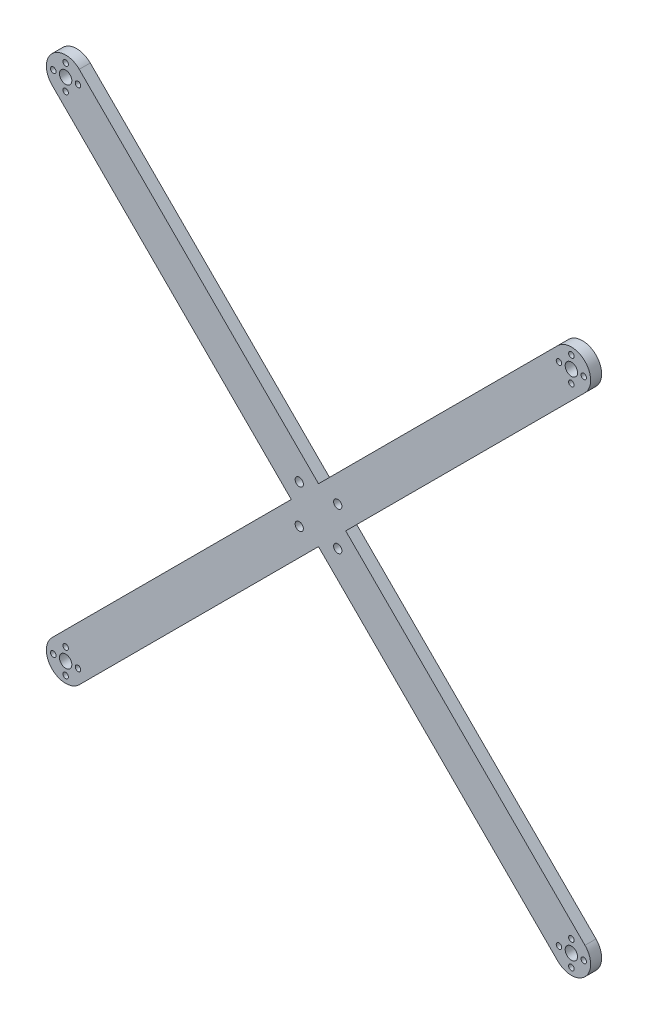
from build123d import *

# Parameters (mm, degrees)
CROQUIS1_R              = 1.5
CROQUIS1_R_2            = 1
CROQUIS1_R_3            = 1.004910311
CROQUIS1_R_4            = 2.25
SALIENTE_EXTRUIR1_DEPTH = 4


with BuildPart() as part:
    # Croquis1 → Saliente-Extruir1 (new body)
    with BuildSketch(Plane.XY):
        with BuildLine():
            Line((-72.974134086, -82.873629023), (14, 4.100505063))
            Line((14, 4.100505063), (100.974134086, -82.873629023))
            ThreePointArc((100.974134086, -82.873629023), (110.873629023, -82.873629023), (110.873629023, -72.974134086))
            Line((110.873629023, -72.974134086), (23.899494937, 14))
            Line((23.899494937, 14), (110.873629023, 100.974134086))
            ThreePointArc((110.873629023, 100.974134086), (110.873629023, 110.873629023), (100.974134086, 110.873629023))
            Line((100.974134086, 110.873629023), (14, 23.899494937))
            Line((14, 23.899494937), (-72.974134086, 110.873629023))
            ThreePointArc((-72.974134086, 110.873629023), (-82.873629023, 110.873629023), (-82.873629023, 100.974134086))
            Line((-82.873629023, 100.974134086), (4.100505063, 14))
            Line((4.100505063, 14), (-82.873629023, -72.974134086))
            ThreePointArc((-82.873629023, -72.974134086), (-82.873629023, -82.873629023), (-72.974134086, -82.873629023))
        make_face()
        with Locations((7, 7)):
            Circle(CROQUIS1_R, mode=Mode.SUBTRACT)
        with Locations((21, 7)):
            Circle(CROQUIS1_R, mode=Mode.SUBTRACT)
        with Locations((-73.423881554, -77.923881554)):
            Circle(CROQUIS1_R_2, mode=Mode.SUBTRACT)
        with Locations((-77.923881554, -82.423881554)):
            Circle(CROQUIS1_R_3, mode=Mode.SUBTRACT)
        with Locations((-82.423881554, -77.923881554)):
            Circle(CROQUIS1_R_2, mode=Mode.SUBTRACT)
        with Locations((-77.923881554, -73.423881554)):
            Circle(CROQUIS1_R_2, mode=Mode.SUBTRACT)
        with Locations((7, 21)):
            Circle(CROQUIS1_R, mode=Mode.SUBTRACT)
        with Locations((110.423881554, -77.923881554)):
            Circle(CROQUIS1_R_2, mode=Mode.SUBTRACT)
        with Locations((105.923881554, -82.423881554)):
            Circle(CROQUIS1_R_2, mode=Mode.SUBTRACT)
        with Locations((101.423881554, -77.923881554)):
            Circle(CROQUIS1_R_2, mode=Mode.SUBTRACT)
        with Locations((105.923881554, -73.423881554)):
            Circle(CROQUIS1_R_2, mode=Mode.SUBTRACT)
        with Locations((-73.423881554, 105.923881554)):
            Circle(CROQUIS1_R_2, mode=Mode.SUBTRACT)
        with Locations((-77.923881554, 101.423881554)):
            Circle(CROQUIS1_R_2, mode=Mode.SUBTRACT)
        with Locations((-82.423881554, 105.923881554)):
            Circle(CROQUIS1_R_2, mode=Mode.SUBTRACT)
        with Locations((-77.923881554, 110.423881554)):
            Circle(CROQUIS1_R_2, mode=Mode.SUBTRACT)
        with Locations((21, 21)):
            Circle(CROQUIS1_R, mode=Mode.SUBTRACT)
        with Locations((110.423881554, 105.923881554)):
            Circle(CROQUIS1_R_2, mode=Mode.SUBTRACT)
        with Locations((105.923881554, 101.423881554)):
            Circle(CROQUIS1_R_2, mode=Mode.SUBTRACT)
        with Locations((101.423881554, 105.923881554)):
            Circle(CROQUIS1_R_2, mode=Mode.SUBTRACT)
        with Locations((105.923881554, 110.423881554)):
            Circle(CROQUIS1_R_2, mode=Mode.SUBTRACT)
        with Locations((-77.923881554, -77.923881554)):
            Circle(CROQUIS1_R_4, mode=Mode.SUBTRACT)
        with Locations((105.923881554, -77.923881554)):
            Circle(CROQUIS1_R_4, mode=Mode.SUBTRACT)
        with Locations((105.923881554, 105.923881554)):
            Circle(CROQUIS1_R_4, mode=Mode.SUBTRACT)
        with Locations((-77.923881554, 105.923881554)):
            Circle(CROQUIS1_R_4, mode=Mode.SUBTRACT)
    extrude(amount=SALIENTE_EXTRUIR1_DEPTH)


solid = part.part
